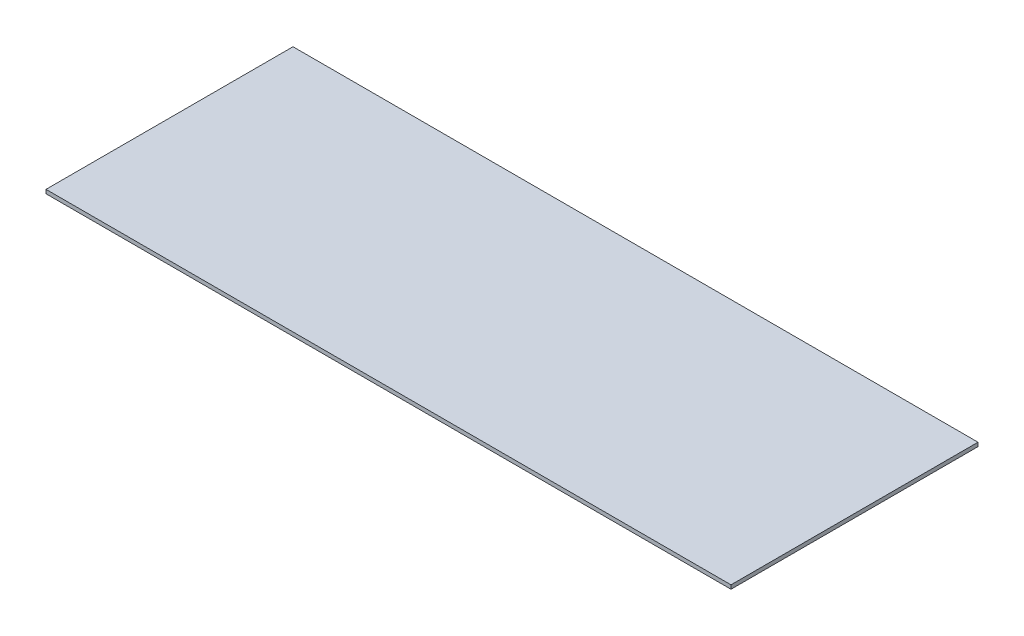
from build123d import *

# Parameters (mm, degrees)
SKETCH1_W           = 44.37
SKETCH1_H           = 16
BOSS_EXTRUDE1_DEPTH = 0.25


with BuildPart() as part:
    # Sketch1 → Boss-Extrude1 (new body)
    with BuildSketch(Plane(origin=(0, 0, 0), x_dir=(1, 0, 0), z_dir=(0, 1, 0))):
        Rectangle(SKETCH1_W, SKETCH1_H)
    extrude(amount=BOSS_EXTRUDE1_DEPTH)


solid = part.part
